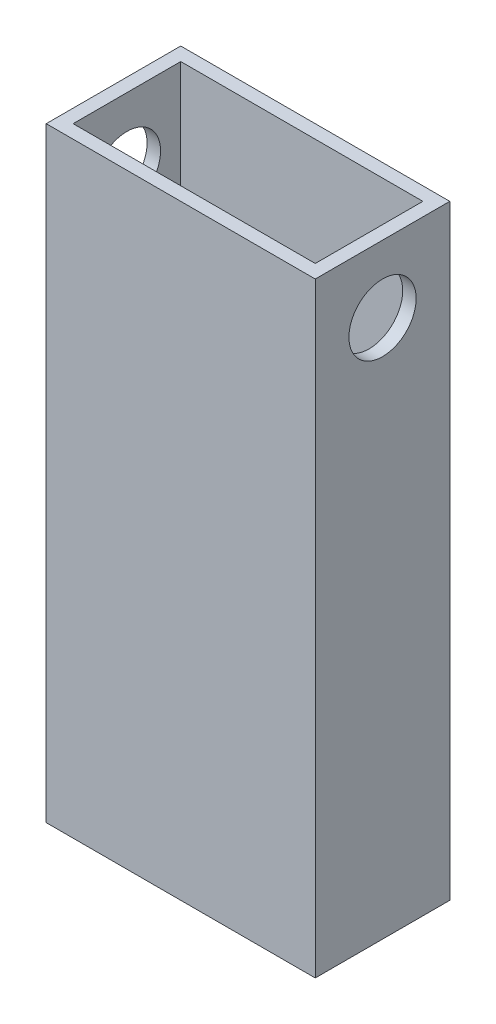
from build123d import *

# Parameters (mm, degrees)
SKETCH1_W           = 50.8
SKETCH1_H           = 25.4
SKETCH1_W_2         = 45.72
SKETCH1_H_2         = 20.32
EXTRUDE_THIN1_DEPTH = 114.3
SKETCH2_R           = 6.35
CUT_EXTRUDE1_DEPTH  = 51.8


with BuildPart() as part:
    # Sketch1 → Extrude-Thin1 (new body)
    with BuildSketch(Plane(origin=(0, 0, 0), x_dir=(1, 0, 0), z_dir=(0, 1, 0))):
        with Locations((25.4, 12.7)):
            Rectangle(SKETCH1_W, SKETCH1_H)
        with Locations((25.4, 12.7)):
            Rectangle(SKETCH1_W_2, SKETCH1_H_2, mode=Mode.SUBTRACT)
    extrude(amount=EXTRUDE_THIN1_DEPTH)

    # Sketch2 → Cut-Extrude1 (cut, through all)
    with BuildSketch(Plane(origin=(50.8, 0, 0), x_dir=(0, 0, -1), z_dir=(1, 0, 0))):
        with Locations((12.7, 101.6)):
            Circle(SKETCH2_R)
    extrude(amount=-CUT_EXTRUDE1_DEPTH, mode=Mode.SUBTRACT)


solid = part.part
